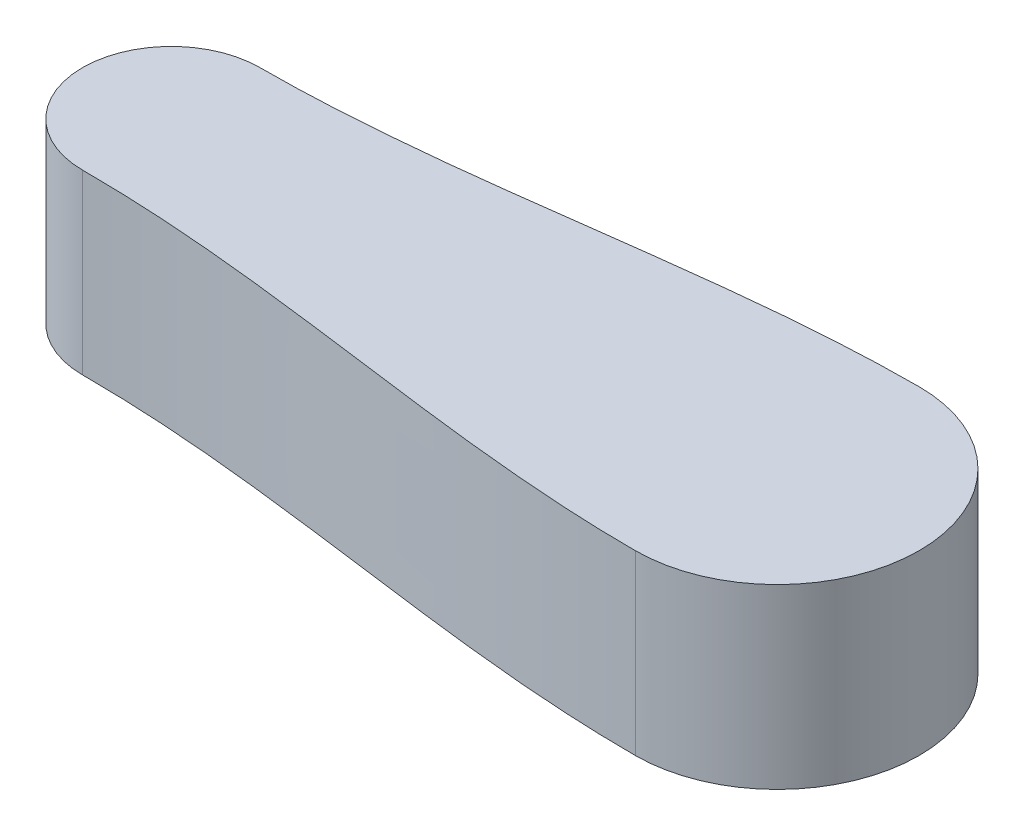
from build123d import *

# Parameters (mm, degrees)
BOSS_EXTRUDE1_DEPTH   = 50
M5_TAPPED_HOLE1_D     = 4.2
M5_TAPPED_HOLE1_DEPTH = 14
M5_TAPPED_HOLE1_TIP   = 1.2618073


with BuildPart() as part:
    # Sketch1 → Boss-Extrude1 (new body)
    with BuildSketch(Plane(origin=(0, 0, 0), x_dir=(1, 0, 0), z_dir=(0, 1, 0))):
        with BuildLine():
            ThreePointArc((25, 50), (0, 25), (25, 0))
            add(Edge.make_bspline(
                [(25, 0), (82.580830765, 0), (138.63084141, -15), (195.775010008, -15)],
                knots=[0, 0, 0, 0, 1, 1, 1, 1], degree=3))
            ThreePointArc((195.775010008, -15), (235.775010008, 25), (195.775010008, 65))
            add(Edge.make_bspline(
                [(25, 50), (82.580830765, 50), (138.63084141, 65), (195.775010008, 65)],
                knots=[0, 0, 0, 0, 1, 1, 1, 1], degree=3))
        make_face()
    extrude(amount=BOSS_EXTRUDE1_DEPTH)

    # M5 Tapped Hole1
    with Locations(Plane(origin=(0, 0, 0), x_dir=(-1, 0, 0), z_dir=(0, -1, 0))):
        with Locations((-162.775010008, 3), (-162.775010008, 47)):
            Hole(M5_TAPPED_HOLE1_D / 2, depth=M5_TAPPED_HOLE1_DEPTH)
            with Locations((0, 0, -(M5_TAPPED_HOLE1_DEPTH + M5_TAPPED_HOLE1_TIP / 2))):  # 118° drill point
                Cone(0, M5_TAPPED_HOLE1_D / 2, M5_TAPPED_HOLE1_TIP, mode=Mode.SUBTRACT)


solid = part.part
